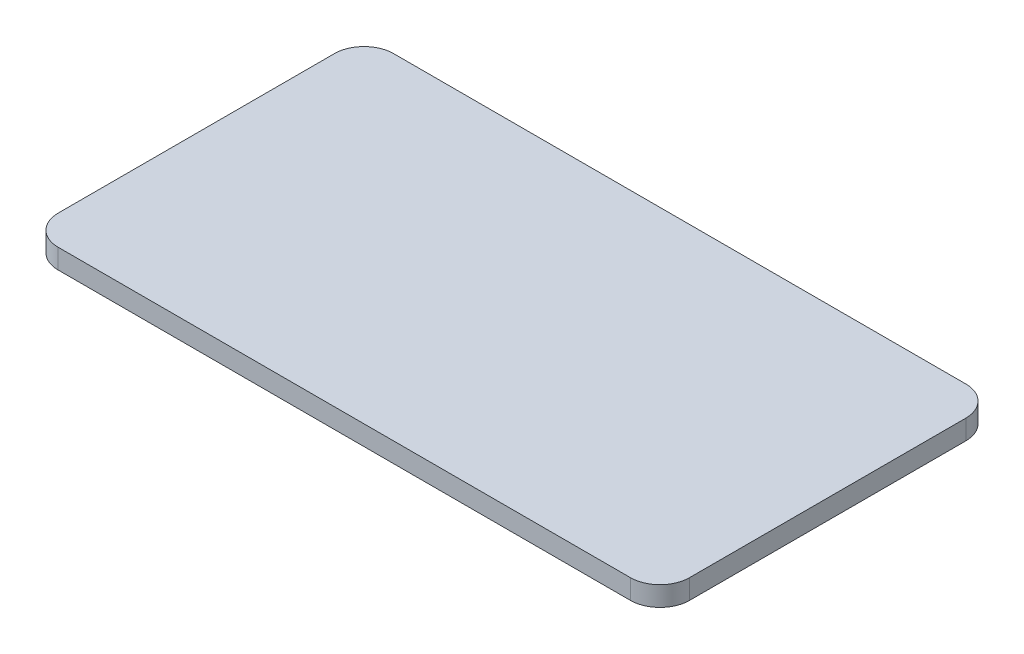
from build123d import *

# Parameters (mm, degrees)
BOSS_EXTRUDE1_DEPTH = 2


with BuildPart() as part:
    # Sketch1 → Boss-Extrude1 (new body)
    with BuildSketch(Plane(origin=(0, 0, 0), x_dir=(1, 0, 0), z_dir=(0, 1, 0))):
        with BuildLine():
            Line((3, 0), (61, 0))
            ThreePointArc((61, 0), (63.121320344, 0.878679656), (64, 3))
            Line((64, 3), (64, 31))
            ThreePointArc((64, 31), (63.121320344, 33.121320344), (61, 34))
            Line((61, 34), (3, 34))
            ThreePointArc((3, 34), (0.878679656, 33.121320344), (0, 31))
            Line((0, 31), (0, 3))
            ThreePointArc((0, 3), (0.878679656, 0.878679656), (3, 0))
        make_face()
    extrude(amount=BOSS_EXTRUDE1_DEPTH)


solid = part.part
